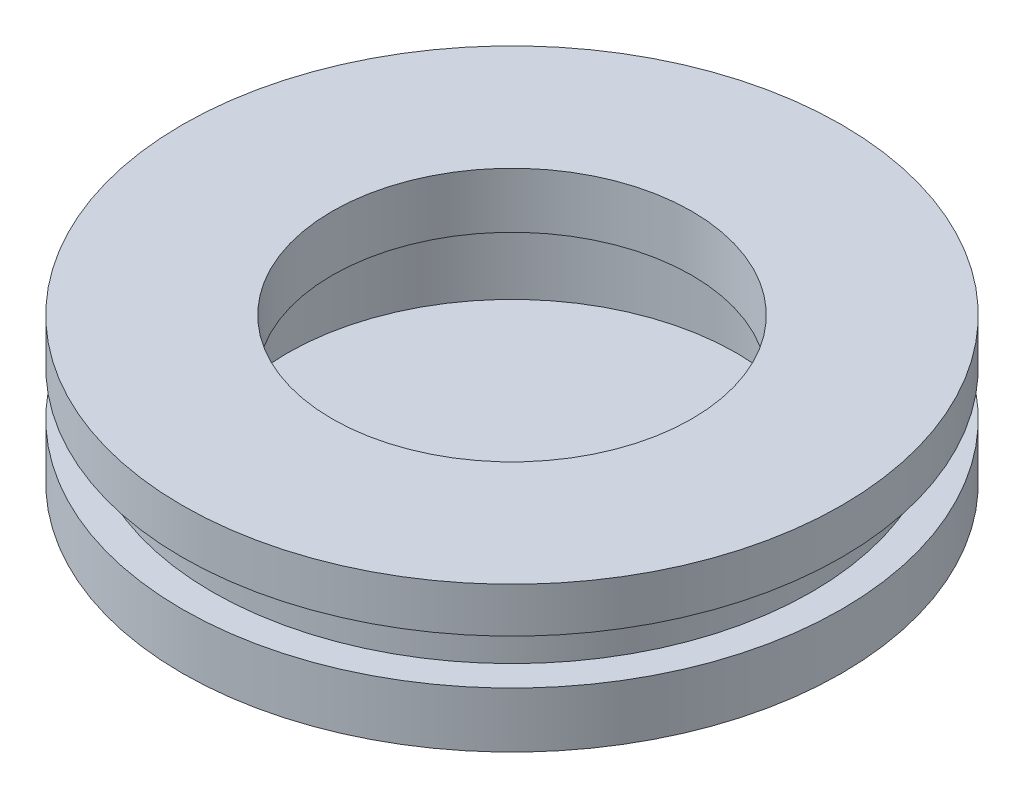
from build123d import *


with BuildPart() as part:
    # Sketch2 → Revolve1 (revolve)
    with BuildSketch(Plane.XY):
        Polygon((0, 0), (0, 8.853672577), (-11, 8.853672577), (-11, 7.353672577), (-10, 7.353672577), (-10, 5.853672577), (-11, 5.853672577), (-11, 4.003672577), align=None)
    revolve(axis=Axis((0, 0, 0), (0, 1, 0)))

    # Sketch3 → Cut-Revolve1 (revolve, cut)
    with BuildSketch(Plane.XY):
        Polygon((-7.5, 7.003672577), (-7.5, 4.003672577), (0, 4.003672577), (0, 10.003672577), (-6, 10.003672577), (-6, 7.003672577), align=None)
    revolve(axis=Axis((0, 4.003672577, 0), (0, 1, 0)), mode=Mode.SUBTRACT)


solid = part.part
